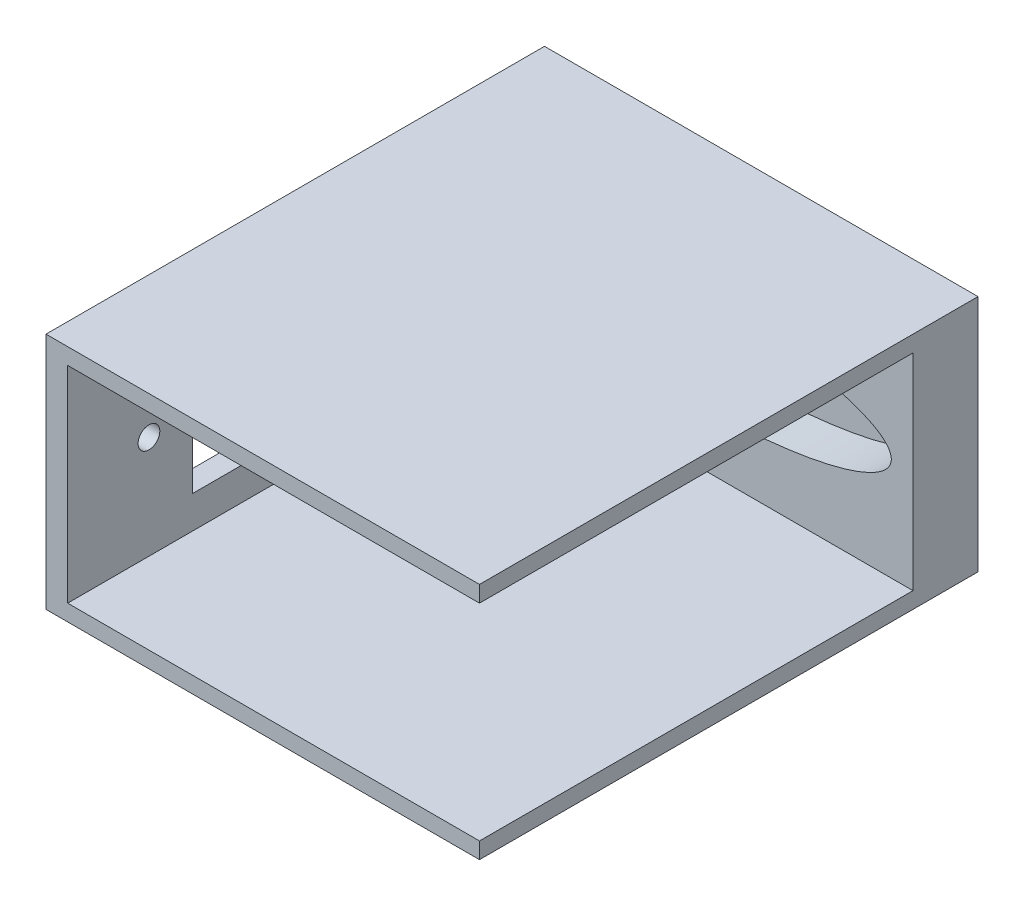
from build123d import *

# Parameters (mm, degrees)
SKETCH_1_W          = 40
SKETCH_1_H          = 22
SKETCH_1_R          = 4.5
EXTRUDE_1_DEPTH     = 6
CUT_EXTRUDE_2_DEPTH = 4
SKETCH_4_R          = 4.5
CUT_EXTRUDE_3_DEPTH = 7
EXTRUDE_2_DEPTH     = 40
SKETCH_6_W          = 23
SKETCH_6_H          = 13
CUT_EXTRUDE_4_DEPTH = 40
SKETCH_7_R          = 1
CUT_EXTRUDE_5_DEPTH = 40


with BuildPart() as part:
    # 草图1 → 凸台-拉伸1 (new body)
    with BuildSketch(Plane.XY):
        Rectangle(SKETCH_1_W, SKETCH_1_H)
        with BuildLine():
            add(Edge.make_bspline(
                [(3.991210712, -4.387982431), (18, -3.591602336), (18, 0), (18, 3.591602336), (3.991210712, 4.387982431)],
                knots=[4.935981285, 4.935981285, 4.935981285, 6.283185307, 6.283185307, 7.630389329, 7.630389329, 7.630389329], degree=2, weights=[1, 0.781579788, 1, 0.781579788, 1]))
            add(Edge.make_bspline(
                [(3.991210712, 4.387982431), (0, 20.567539049), (-3.991210712, 4.387982431)],
                knots=[5.192517184, 5.192517184, 5.192517184, 7.373853431, 7.373853431, 7.373853431], degree=2, weights=[1, 0.461892887, 1]))
            add(Edge.make_bspline(
                [(-3.991210712, 4.387982431), (-18, 3.591602336), (-18, 0), (-18, -3.591602336), (-3.991210712, -4.387982431)],
                knots=[1.794388632, 1.794388632, 1.794388632, 3.141592654, 3.141592654, 4.488796676, 4.488796676, 4.488796676], degree=2, weights=[1, 0.781579788, 1, 0.781579788, 1]))
            add(Edge.make_bspline(
                [(-3.991210712, -4.387982431), (0, -20.567539049), (3.991210712, -4.387982431)],
                knots=[2.05092453, 2.05092453, 2.05092453, 4.232260777, 4.232260777, 4.232260777], degree=2, weights=[1, 0.461892887, 1]))
        make_face(mode=Mode.SUBTRACT)
        with BuildLine():
            add(Edge.make_bspline(
                [(-3.991210712, -4.387982431), (0, -20.567539049), (3.991210712, -4.387982431)],
                knots=[2.05092453, 2.05092453, 2.05092453, 4.232260777, 4.232260777, 4.232260777], degree=2, weights=[1, 0.461892887, 1]))
            add(Edge.make_bspline(
                [(3.991210712, -4.387982431), (18, -3.591602336), (18, 0), (18, 3.591602336), (3.991210712, 4.387982431)],
                knots=[4.935981285, 4.935981285, 4.935981285, 6.283185307, 6.283185307, 7.630389329, 7.630389329, 7.630389329], degree=2, weights=[1, 0.781579788, 1, 0.781579788, 1]))
            add(Edge.make_bspline(
                [(3.991210712, 4.387982431), (0, 20.567539049), (-3.991210712, 4.387982431)],
                knots=[5.192517184, 5.192517184, 5.192517184, 7.373853431, 7.373853431, 7.373853431], degree=2, weights=[1, 0.461892887, 1]))
            add(Edge.make_bspline(
                [(-3.991210712, 4.387982431), (-18, 3.591602336), (-18, 0), (-18, -3.591602336), (-3.991210712, -4.387982431)],
                knots=[1.794388632, 1.794388632, 1.794388632, 3.141592654, 3.141592654, 4.488796676, 4.488796676, 4.488796676], degree=2, weights=[1, 0.781579788, 1, 0.781579788, 1]))
        make_face()
        Circle(SKETCH_1_R, mode=Mode.SUBTRACT)
        Circle(SKETCH_1_R)
    extrude(amount=EXTRUDE_1_DEPTH)

    # 草图3 → 切除-拉伸2 (cut)
    with BuildSketch(Plane.XY.offset(6)):
        with BuildLine():
            add(Edge.make_bspline(
                [(3.991210712, -4.387982431), (18, -3.591602336), (18, 0), (18, 3.591602336), (3.991210712, 4.387982431)],
                knots=[4.935981285, 4.935981285, 4.935981285, 6.283185307, 6.283185307, 7.630389329, 7.630389329, 7.630389329], degree=2, weights=[1, 0.781579788, 1, 0.781579788, 1]))
            add(Edge.make_bspline(
                [(3.991210712, 4.387982431), (0, 20.567539049), (-3.991210712, 4.387982431)],
                knots=[5.192517184, 5.192517184, 5.192517184, 7.373853431, 7.373853431, 7.373853431], degree=2, weights=[1, 0.461892887, 1]))
            add(Edge.make_bspline(
                [(-3.991210712, 4.387982431), (-18, 3.591602336), (-18, 0), (-18, -3.591602336), (-3.991210712, -4.387982431)],
                knots=[1.794388632, 1.794388632, 1.794388632, 3.141592654, 3.141592654, 4.488796676, 4.488796676, 4.488796676], degree=2, weights=[1, 0.781579788, 1, 0.781579788, 1]))
            add(Edge.make_bspline(
                [(-3.991210712, -4.387982431), (0, -20.567539049), (3.991210712, -4.387982431)],
                knots=[2.05092453, 2.05092453, 2.05092453, 4.232260777, 4.232260777, 4.232260777], degree=2, weights=[1, 0.461892887, 1]))
        make_face()
    extrude(amount=-CUT_EXTRUDE_2_DEPTH, mode=Mode.SUBTRACT)

    # 草图4 → 切除-拉伸3 (cut, through all)
    with BuildSketch(Plane.XY.offset(6)):
        Circle(SKETCH_4_R)
    extrude(amount=-CUT_EXTRUDE_3_DEPTH, mode=Mode.SUBTRACT)

    # 草图5 → 凸台-拉伸2 (add)
    with BuildSketch(Plane.XY.offset(6)):
        Polygon((20, -11), (-20, -11), (-20, -9.5), (-20, 9.5), (-20, 11), (20, 11), (20, 9.5), (-18, 9.5), (-18, -9.5), (20, -9.5), align=None)
    extrude(amount=EXTRUDE_2_DEPTH)

    # 草图6 → 切除-拉伸4 (cut)
    with BuildSketch(Plane.ZY.offset(20)):
        with Locations((23, 0)):
            Rectangle(SKETCH_6_W, SKETCH_6_H)
    extrude(amount=-CUT_EXTRUDE_4_DEPTH, mode=Mode.SUBTRACT)

    # 草图7 → 切除-拉伸5 (cut)
    with BuildSketch(Plane.ZY.offset(20)):
        with Locations((38.5, 0)):
            Circle(SKETCH_7_R)
        with Locations((7.5, 0)):
            Circle(SKETCH_7_R)
    extrude(amount=-CUT_EXTRUDE_5_DEPTH, mode=Mode.SUBTRACT)


solid = part.part
